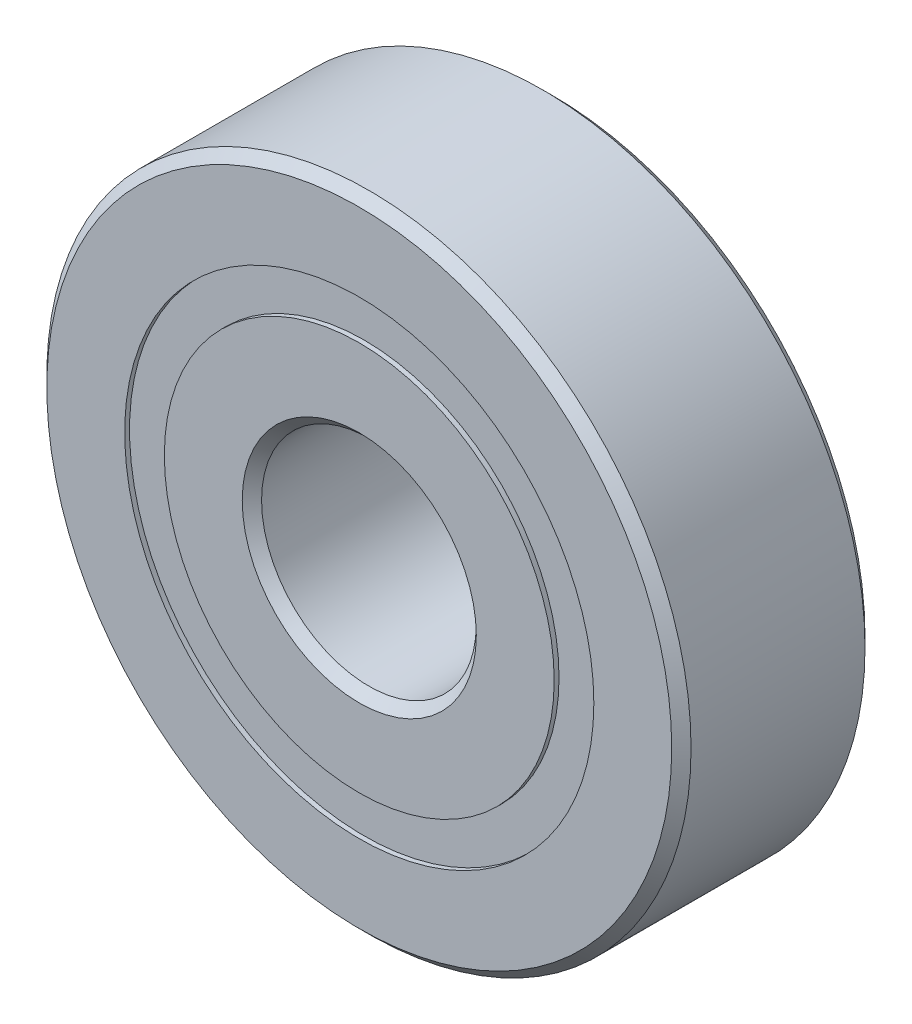
from build123d import *

# Parameters (mm, degrees)
CIRPATTERN1_COUNT = 12
SKETCH5_W         = 2.072258298
SKETCH5_H         = 1.846153846


with BuildPart() as part:
    # Sketch1 → Revolve1 (revolve)
    with BuildSketch(Plane(origin=(0, 0, 0), x_dir=(0, 0, -1), z_dir=(1, 0, 0))):
        with BuildLine():
            Line((4.05, 15), (-4.05, 15))
            Line((-4.05, 15), (-4.5, 14.55))
            Line((-4.5, 14.55), (-4.5, 10.923076923))
            Line((-4.5, 10.923076923), (-2, 10.923076923))
            ThreePointArc((-2, 10.923076923), (0, 12.202741702), (2, 10.923076923))
            Line((2, 10.923076923), (4.5, 10.923076923))
            Line((4.5, 10.923076923), (4.5, 14.55))
            Line((4.5, 14.55), (4.05, 15))
        make_face()
    revolve(axis=Axis((0, 0, 4.5), (0, 0, -1)))


with BuildPart() as body_2:
    # Sketch3 → Revolve3 (revolve)
    with BuildSketch(Plane(origin=(0, 0, 0), x_dir=(0, 0, -1), z_dir=(1, 0, 0))):
        with BuildLine():
            Line((-4.5, 9.076923077), (-2, 9.076923077))
            ThreePointArc((-2, 9.076923077), (0, 7.797258298), (2, 9.076923077))
            Line((2, 9.076923077), (4.5, 9.076923077))
            Line((4.5, 9.076923077), (4.5, 5.45))
            Line((4.5, 5.45), (4.05, 5))
            Line((4.05, 5), (-4.05, 5))
            Line((-4.05, 5), (-4.5, 5.45))
            Line((-4.5, 5.45), (-4.5, 9.076923077))
        make_face()
    revolve(axis=Axis((0, 0, 4.5), (0, 0, -1)))


with BuildPart() as body_3:
    # Sketch4 → Revolve4 (revolve)
    with BuildSketch(Plane(origin=(0, 0, 0), x_dir=(0, 0, -1), z_dir=(1, 0, 0))):
        with BuildLine():
            Line((-2.202741702, 10), (2.202741702, 10))
            ThreePointArc((2.202741702, 10), (0, 12.202741702), (-2.202741702, 10))
        make_face()
    revolve(axis=Axis((0, 10, 2.202741702), (0, 0, -1)))


with BuildPart() as cirpattern1_1:
    # CirPattern1: pattern copy
    add(body_3.part.rotate(Axis((0, 0, -4.5), (0, 0, 1)), 1 * 360 / CIRPATTERN1_COUNT))


with BuildPart() as cirpattern1_2:
    # CirPattern1: pattern copy
    add(body_3.part.rotate(Axis((0, 0, -4.5), (0, 0, 1)), 2 * 360 / CIRPATTERN1_COUNT))


with BuildPart() as cirpattern1_3:
    # CirPattern1: pattern copy
    add(body_3.part.rotate(Axis((0, 0, -4.5), (0, 0, 1)), 3 * 360 / CIRPATTERN1_COUNT))


with BuildPart() as cirpattern1_4:
    # CirPattern1: pattern copy
    add(body_3.part.rotate(Axis((0, 0, -4.5), (0, 0, 1)), 4 * 360 / CIRPATTERN1_COUNT))


with BuildPart() as cirpattern1_5:
    # CirPattern1: pattern copy
    add(body_3.part.rotate(Axis((0, 0, -4.5), (0, 0, 1)), 5 * 360 / CIRPATTERN1_COUNT))


with BuildPart() as cirpattern1_6:
    # CirPattern1: pattern copy
    add(body_3.part.rotate(Axis((0, 0, -4.5), (0, 0, 1)), 6 * 360 / CIRPATTERN1_COUNT))


with BuildPart() as cirpattern1_7:
    # CirPattern1: pattern copy
    add(body_3.part.rotate(Axis((0, 0, -4.5), (0, 0, 1)), 7 * 360 / CIRPATTERN1_COUNT))


with BuildPart() as cirpattern1_8:
    # CirPattern1: pattern copy
    add(body_3.part.rotate(Axis((0, 0, -4.5), (0, 0, 1)), 8 * 360 / CIRPATTERN1_COUNT))


with BuildPart() as cirpattern1_9:
    # CirPattern1: pattern copy
    add(body_3.part.rotate(Axis((0, 0, -4.5), (0, 0, 1)), 9 * 360 / CIRPATTERN1_COUNT))


with BuildPart() as cirpattern1_10:
    # CirPattern1: pattern copy
    add(body_3.part.rotate(Axis((0, 0, -4.5), (0, 0, 1)), 10 * 360 / CIRPATTERN1_COUNT))


with BuildPart() as cirpattern1_11:
    # CirPattern1: pattern copy
    add(body_3.part.rotate(Axis((0, 0, -4.5), (0, 0, 1)), 11 * 360 / CIRPATTERN1_COUNT))


with BuildPart() as body_15:
    # Sketch5 → Revolve5 (revolve)
    with BuildSketch(Plane(origin=(0, 0, 0), x_dir=(0, 0, -1), z_dir=(1, 0, 0))):
        with Locations((-3.238870851, 10)):
            Rectangle(SKETCH5_W, SKETCH5_H)
        with Locations((3.238870851, 10)):
            Rectangle(SKETCH5_W, SKETCH5_H)
    revolve(axis=Axis((0, 0, 4.5), (0, 0, -1)))


solid = Compound([part.part, body_2.part, body_3.part, cirpattern1_1.part, cirpattern1_2.part, cirpattern1_3.part, cirpattern1_4.part, cirpattern1_5.part, cirpattern1_6.part, cirpattern1_7.part, cirpattern1_8.part, cirpattern1_9.part, cirpattern1_10.part, cirpattern1_11.part, body_15.part])
